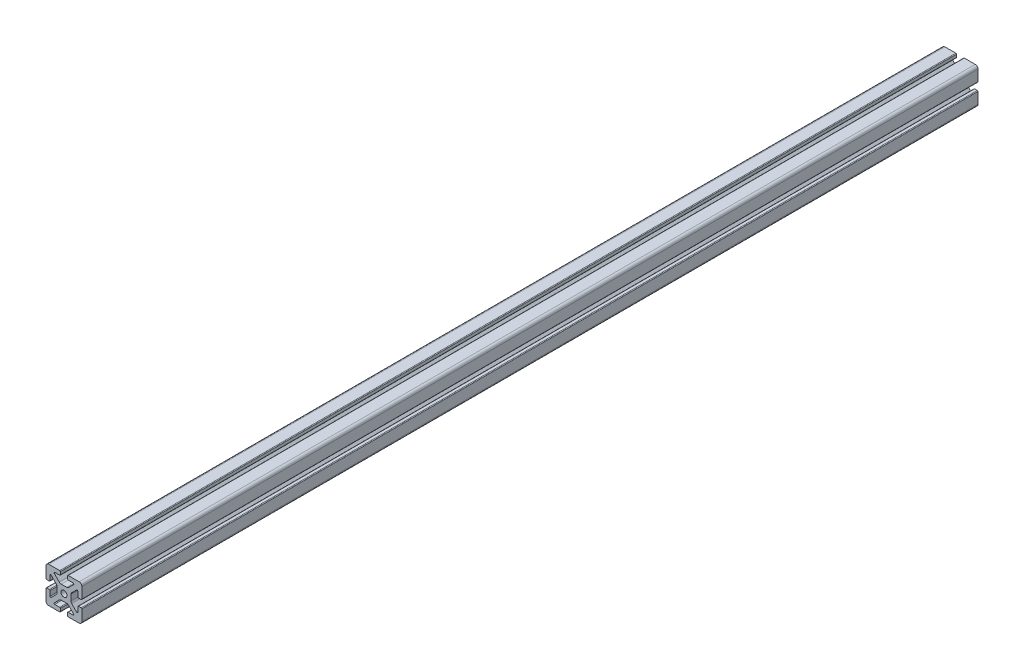
from build123d import *

# Parameters (mm, degrees)
SKETCH1_R           = 3.4036
BOSS_EXTRUDE1_DEPTH = 500


with BuildPart() as part:
    # Sketch1 → Boss-Extrude1 (new body, symmetric)
    with BuildSketch(Plane.XY):
        with BuildLine():
            Line((-20, 16.952), (-20, 4.7625))
            ThreePointArc((-20, 4.7625), (-19.776815367, 4.223684633), (-19.238, 4.0005))
            Line((-19.238, 4.0005), (-16.2662, 4.0005))
            ThreePointArc((-16.2662, 4.0005), (-15.727384633, 4.223684633), (-15.5042, 4.7625))
            Line((-15.5042, 4.7625), (-15.5042, 10.2235))
            ThreePointArc((-15.5042, 10.2235), (-15.033804775, 10.927496204), (-14.203384633, 10.762315367))
            Line((-14.203384633, 10.762315367), (-8.635059555, 5.19399029))
            ThreePointArc((-8.635059555, 5.19399029), (-7.985348265, 4.221628629), (-7.7572, 3.074649845))
            Line((-7.7572, 3.074649845), (-7.7572, -3.074649845))
            ThreePointArc((-7.7572, -3.074649845), (-7.985348265, -4.221628629), (-8.635059555, -5.19399029))
            Line((-8.635059555, -5.19399029), (-14.203384633, -10.762315367))
            ThreePointArc((-14.203384633, -10.762315367), (-15.033804775, -10.927496204), (-15.5042, -10.2235))
            Line((-15.5042, -10.2235), (-15.5042, -4.7625))
            ThreePointArc((-15.5042, -4.7625), (-15.727384633, -4.223684633), (-16.2662, -4.0005))
            Line((-16.2662, -4.0005), (-19.238, -4.0005))
            ThreePointArc((-19.238, -4.0005), (-19.776815367, -4.223684633), (-20, -4.7625))
            Line((-20, -4.7625), (-20, -16.952))
            ThreePointArc((-20, -16.952), (-19.107261469, -19.107261469), (-16.952, -20))
            Line((-16.952, -20), (-4.7625, -20))
            ThreePointArc((-4.7625, -20), (-4.223684633, -19.776815367), (-4.0005, -19.238))
            Line((-4.0005, -19.238), (-4.0005, -16.2662))
            ThreePointArc((-4.0005, -16.2662), (-4.223684633, -15.727384633), (-4.7625, -15.5042))
            Line((-4.7625, -15.5042), (-10.2235, -15.5042))
            ThreePointArc((-10.2235, -15.5042), (-10.927496204, -15.033804775), (-10.762315367, -14.203384633))
            Line((-10.762315367, -14.203384633), (-5.19399029, -8.635059555))
            ThreePointArc((-5.19399029, -8.635059555), (-4.221628629, -7.985348265), (-3.074649845, -7.7572))
            Line((-3.074649845, -7.7572), (3.074649845, -7.7572))
            ThreePointArc((3.074649845, -7.7572), (4.221628629, -7.985348265), (5.19399029, -8.635059555))
            Line((5.19399029, -8.635059555), (10.762315367, -14.203384633))
            ThreePointArc((10.762315367, -14.203384633), (10.927496204, -15.033804775), (10.2235, -15.5042))
            Line((10.2235, -15.5042), (4.7625, -15.5042))
            ThreePointArc((4.7625, -15.5042), (4.223684633, -15.727384633), (4.0005, -16.2662))
            Line((4.0005, -16.2662), (4.0005, -19.238))
            ThreePointArc((4.0005, -19.238), (4.223684633, -19.776815367), (4.7625, -20))
            Line((4.7625, -20), (16.952, -20))
            ThreePointArc((16.952, -20), (19.107261469, -19.107261469), (20, -16.952))
            Line((20, -16.952), (20, -4.7625))
            ThreePointArc((20, -4.7625), (19.776815367, -4.223684633), (19.238, -4.0005))
            Line((19.238, -4.0005), (16.2662, -4.0005))
            ThreePointArc((16.2662, -4.0005), (15.727384633, -4.223684633), (15.5042, -4.7625))
            Line((15.5042, -4.7625), (15.5042, -10.2235))
            ThreePointArc((15.5042, -10.2235), (15.033804775, -10.927496204), (14.203384633, -10.762315367))
            Line((14.203384633, -10.762315367), (8.635059555, -5.19399029))
            ThreePointArc((8.635059555, -5.19399029), (7.985348265, -4.221628629), (7.7572, -3.074649845))
            Line((7.7572, -3.074649845), (7.7572, 3.074649845))
            ThreePointArc((7.7572, 3.074649845), (7.985348265, 4.221628629), (8.635059555, 5.19399029))
            Line((8.635059555, 5.19399029), (14.203384633, 10.762315367))
            ThreePointArc((14.203384633, 10.762315367), (15.033804775, 10.927496204), (15.5042, 10.2235))
            Line((15.5042, 10.2235), (15.5042, 4.7625))
            ThreePointArc((15.5042, 4.7625), (15.727384633, 4.223684633), (16.2662, 4.0005))
            Line((16.2662, 4.0005), (19.238, 4.0005))
            ThreePointArc((19.238, 4.0005), (19.776815367, 4.223684633), (20, 4.7625))
            Line((20, 4.7625), (20, 16.952))
            ThreePointArc((20, 16.952), (19.107261469, 19.107261469), (16.952, 20))
            Line((16.952, 20), (4.7625, 20))
            ThreePointArc((4.7625, 20), (4.223684633, 19.776815367), (4.0005, 19.238))
            Line((4.0005, 19.238), (4.0005, 16.2662))
            ThreePointArc((4.0005, 16.2662), (4.223684633, 15.727384633), (4.7625, 15.5042))
            Line((4.7625, 15.5042), (10.2235, 15.5042))
            ThreePointArc((10.2235, 15.5042), (10.927496204, 15.033804775), (10.762315367, 14.203384633))
            Line((10.762315367, 14.203384633), (5.19399029, 8.635059555))
            ThreePointArc((5.19399029, 8.635059555), (4.221628629, 7.985348265), (3.074649845, 7.7572))
            Line((3.074649845, 7.7572), (-3.074649845, 7.7572))
            ThreePointArc((-3.074649845, 7.7572), (-4.221628629, 7.985348265), (-5.19399029, 8.635059555))
            Line((-5.19399029, 8.635059555), (-10.762315367, 14.203384633))
            ThreePointArc((-10.762315367, 14.203384633), (-10.927496204, 15.033804775), (-10.2235, 15.5042))
            Line((-10.2235, 15.5042), (-4.7625, 15.5042))
            ThreePointArc((-4.7625, 15.5042), (-4.223684633, 15.727384633), (-4.0005, 16.2662))
            Line((-4.0005, 16.2662), (-4.0005, 19.238))
            ThreePointArc((-4.0005, 19.238), (-4.223684633, 19.776815367), (-4.7625, 20))
            Line((-4.7625, 20), (-16.952, 20))
            ThreePointArc((-16.952, 20), (-19.107261469, 19.107261469), (-20, 16.952))
        make_face()
        Circle(SKETCH1_R, mode=Mode.SUBTRACT)
    extrude(amount=BOSS_EXTRUDE1_DEPTH, both=True)


solid = part.part
